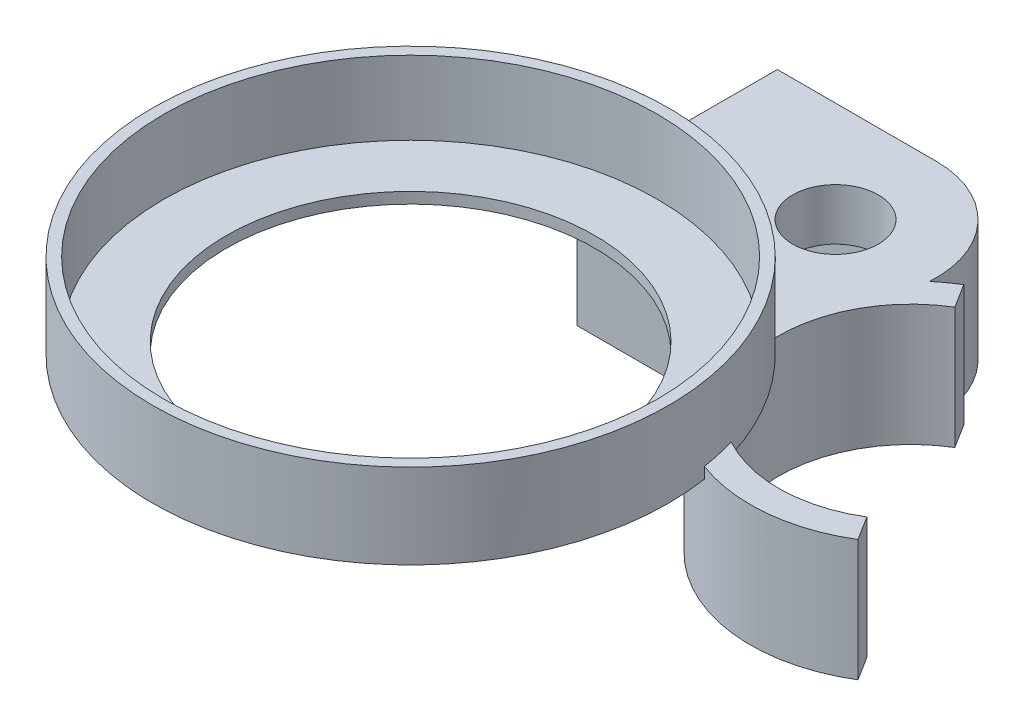
from build123d import *

# Parameters (mm, degrees)
SKETCH1_R           = 50
SKETCH1_R_2         = 11.615083761
BOSS_EXTRUDE1_DEPTH = 3
SKETCH2_R           = 70
SKETCH2_R_2         = 67
BOSS_EXTRUDE3_DEPTH = 20
SKETCH4_R           = 11.615083761
BOSS_EXTRUDE6_DEPTH = 30
CUT_EXTRUDE2_DEPTH  = 19


with BuildPart() as part:
    # Sketch1 → Boss-Extrude1 (new body)
    with BuildSketch(Plane(origin=(0, 0, 0), x_dir=(1, 0, 0), z_dir=(0, 1, 0))):
        with BuildLine():
            Line((61.670303131, 88.507050428), (65.738918694, 82.002662996))
            ThreePointArc((65.738918694, 82.002662996), (52.910005118, 68.514839013), (48.562558373, 50.415056524))
            ThreePointArc((48.562558373, 50.415056524), (59.803165171, 36.381058747), (67.097930635, 19.94662138))
            ThreePointArc((67.097930635, 19.94662138), (85.226692334, 15.486926368), (103.142834496, 20.735995847))
            Line((103.142834496, 20.735995847), (107.211450059, 14.231608415))
            ThreePointArc((107.211450059, 14.231608415), (88.628926733, 8.008407228), (69.198869979, 10.560132275))
            ThreePointArc((69.198869979, 10.560132275), (-39.949778038, -57.480563973), (-14.223379462, 68.539736479))
            Line((-14.223379462, 68.539736479), (-14.223379462, 113.780543001))
            Line((-14.223379462, 113.780543001), (28.94098919, 113.780543001))
            ThreePointArc((28.94098919, 113.780543001), (48.93114235, 105.106024988), (56.25040353, 84.580872081))
            ThreePointArc((56.25040353, 84.580872081), (58.884844334, 86.648197778), (61.670303131, 88.507050428))
        make_face()
        Circle(SKETCH1_R, mode=Mode.SUBTRACT)
        with Locations((28.94098919, 86.409945266)):
            Circle(SKETCH1_R_2, mode=Mode.SUBTRACT)
    extrude(amount=BOSS_EXTRUDE1_DEPTH)

    # Sketch2 → Boss-Extrude3 (add)
    with BuildSketch(Plane(origin=(0, 3, 0), x_dir=(1, 0, 0), z_dir=(0, 1, 0))):
        Circle(SKETCH2_R)
        Circle(SKETCH2_R_2, mode=Mode.SUBTRACT)
    extrude(amount=BOSS_EXTRUDE3_DEPTH)

    # Sketch4 → Boss-Extrude6 (add)
    with BuildSketch(Plane.XZ):
        with BuildLine():
            Line((107.211450059, -14.231608415), (103.142834496, -20.735995847))
            ThreePointArc((103.142834496, -20.735995847), (53.80754302, -32.66737152), (65.738918694, -82.002662996))
            Line((65.738918694, -82.002662996), (61.670303131, -88.507050428))
            ThreePointArc((61.670303131, -88.507050428), (58.884844334, -86.648197778), (56.25040353, -84.580872081))
            ThreePointArc((56.25040353, -84.580872081), (48.93114235, -105.106024988), (28.94098919, -113.780543001))
            Line((28.94098919, -113.780543001), (-14.223379462, -113.780543001))
            Line((-14.223379462, -113.780543001), (-14.223379462, -59.37804429))
            Line((-14.223379462, -59.37804429), (41.620673144, -59.37804429))
            ThreePointArc((41.620673144, -59.37804429), (46.511966871, -29.942543741), (69.198869979, -10.560132275))
            ThreePointArc((69.198869979, -10.560132275), (88.628926733, -8.008407228), (107.211450059, -14.231608415))
        make_face()
        with Locations((28.94098919, -86.409945266)):
            Circle(SKETCH4_R, mode=Mode.SUBTRACT)
    extrude(amount=BOSS_EXTRUDE6_DEPTH)

    # Sketch6 → Cut-Extrude2 (cut)
    with BuildSketch(Plane.XZ.offset(30)):
        with BuildLine():
            Line((28.94098919, -104.597730163), (-14.223379462, -104.597730163))
            Line((-14.223379462, -104.597730163), (-14.223379462, -68.222160369))
            Line((-14.223379462, -68.222160369), (28.94098919, -68.222160369))
            ThreePointArc((28.94098919, -68.222160369), (47.128774087, -86.409945266), (28.94098919, -104.597730163))
        make_face()
    extrude(amount=-CUT_EXTRUDE2_DEPTH, mode=Mode.SUBTRACT)


solid = part.part
